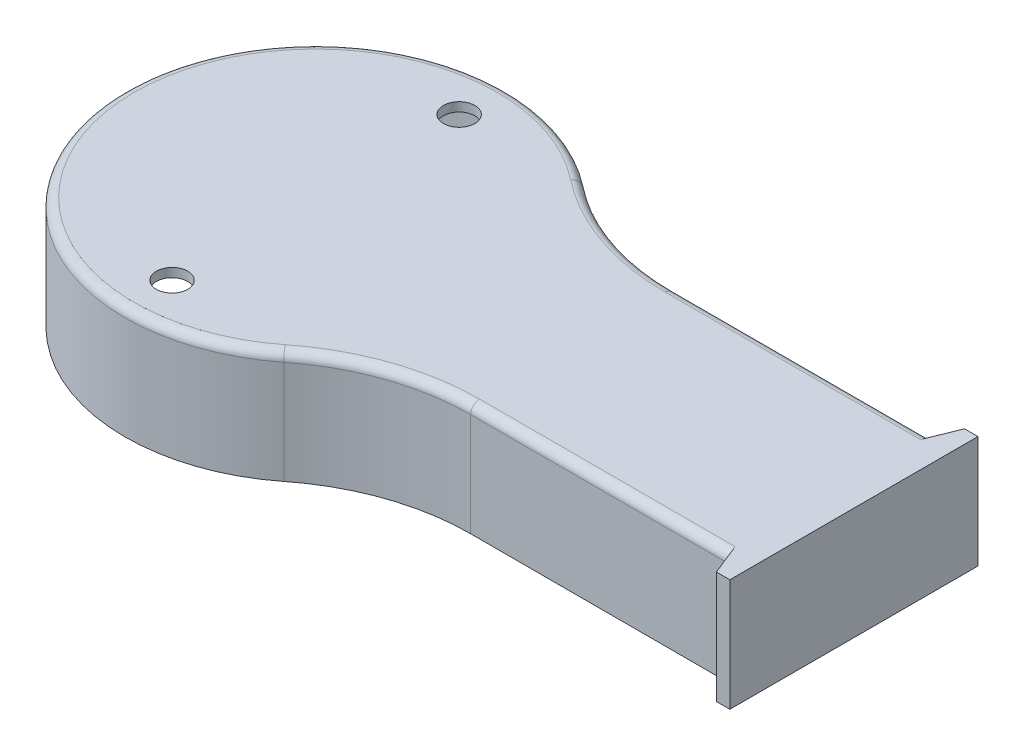
from build123d import *

# Parameters (mm, degrees)
SALIENTE_EXTRUIR1_DEPTH = 25
VACIADO1_T              = -2
CORTAR_EXTRUIR1_REACH   = 27
CROQUIS3_R              = 3.5
SALIENTE_EXTRUIR2_DEPTH = 25
REDONDEO1_R             = 2
REDONDEO2_R             = 2


with BuildPart() as part:
    # Croquis1 → Saliente-Extruir1 (new body)
    with BuildSketch(Plane(origin=(0, 0, 0), x_dir=(1, 0, 0), z_dir=(0, 1, 0))):
        with BuildLine():
            Line((57.240287673, 0), (120, 0))
            Line((120, 0), (120, 45.324457228))
            Line((120, 45.324457228), (57.240287673, 45.324457228))
            ThreePointArc((57.240287673, 45.324457228), (40.867200252, 48.081235404), (26.299591633, 56.047576896))
            ThreePointArc((26.299591633, 56.047576896), (-42.5, 22.662228614), (26.299591633, -10.723119668))
            ThreePointArc((26.299591633, -10.723119668), (40.867200252, -2.756778176), (57.240287673, 0))
        make_face()
    extrude(amount=SALIENTE_EXTRUIR1_DEPTH)

    # Vaciado1
    vaciado1_openings = [part.faces().sort_by_distance(p)[0] for p in [
        (56.079114696, 0, -22.662228614),
    ]]
    offset(amount=VACIADO1_T, openings=vaciado1_openings, kind=Kind.INTERSECTION)

    # Croquis3 → Cortar-Extruir1 (cut, up to next)
    with BuildSketch(Plane(origin=(0, 25, 0), x_dir=(1, 0, 0), z_dir=(0, 1, 0)), mode=Mode.PRIVATE) as cortar_extruir1_sk1:
        with Locations((0, 54.662228614)):
            Circle(CROQUIS3_R)
    cortar_extruir1_tool1 = extrude(cortar_extruir1_sk1.sketch, amount=-CORTAR_EXTRUIR1_REACH, mode=Mode.PRIVATE) & part.part
    add(cortar_extruir1_tool1.solids().sort_by_distance((0, 25, -54.662229))[0], mode=Mode.SUBTRACT)
    # Croquis3 → Cortar-Extruir1 (cut, up to next)
    with BuildSketch(Plane(origin=(0, 25, 0), x_dir=(1, 0, 0), z_dir=(0, 1, 0)), mode=Mode.PRIVATE) as cortar_extruir1_sk2:
        with Locations((0, -9.337771386)):
            Circle(CROQUIS3_R)
    cortar_extruir1_tool2 = extrude(cortar_extruir1_sk2.sketch, amount=-CORTAR_EXTRUIR1_REACH, mode=Mode.PRIVATE) & part.part
    add(cortar_extruir1_tool2.solids().sort_by_distance((0, 25, 9.337771))[0], mode=Mode.SUBTRACT)

    # Croquis4 → Saliente-Extruir2 (add)
    with BuildSketch(Plane(origin=(0, 25, 0), x_dir=(1, 0, 0), z_dir=(0, 1, 0))):
        Polygon((120, 45.324457228), (120, 50.324457228), (117, 50.324457228), (115, 45.324457228), align=None)
        Polygon((115, 0), (120, 0), (120, -5), (117, -5), align=None)
    extrude(amount=-SALIENTE_EXTRUIR2_DEPTH)

    # Redondeo1
    redondeo1_edges = [part.edges().sort_by_distance(p)[0] for p in [
        (40.867200252, 25, 2.756778176),
        (86.120143836, 25, 0),
        (40.867200252, 25, -48.081235404),
        (86.120143836, 25, -45.324457228),
        (-42.5, 25, -22.662228614),
    ]]
    fillet(redondeo1_edges, radius=REDONDEO1_R)

    # Redondeo2
    redondeo2_edges = [part.edges().sort_by_distance(p)[0] for p in [
        (40.212276755, 23, -46.191506531),
        (-40.5, 23, -22.662228614),
        (40.212276755, 23, 0.867049303),
        (87.620143836, 23, -2),
        (118, 23, -22.662228614),
        (87.620143836, 23, -43.324457228),
    ]]
    fillet(redondeo2_edges, radius=REDONDEO2_R)


solid = part.part
